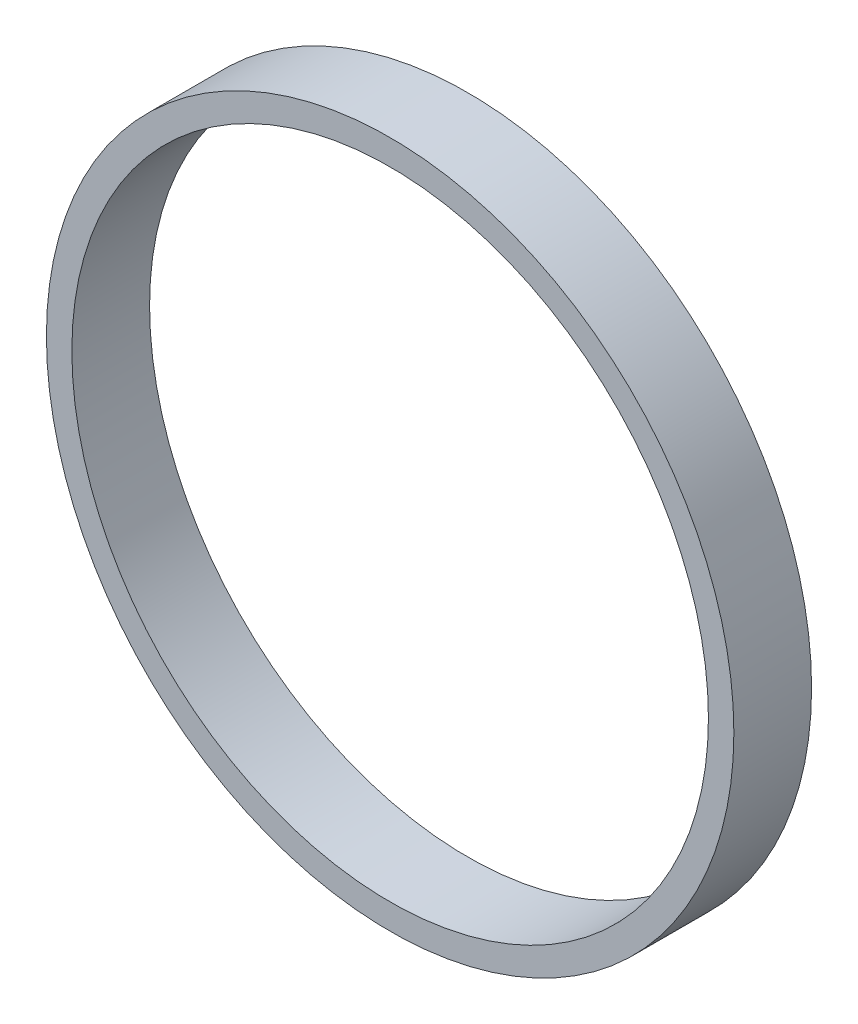
from build123d import *

# Parameters (mm, degrees)
SKETCH1_R           = 24.325
SKETCH1_R_2         = 22.525
BOSS_EXTRUDE1_DEPTH = 5.5


with BuildPart() as part:
    # Sketch1 → Boss-Extrude1 (new body)
    with BuildSketch(Plane.XY):
        Circle(SKETCH1_R)
        Circle(SKETCH1_R_2, mode=Mode.SUBTRACT)
    extrude(amount=BOSS_EXTRUDE1_DEPTH)


solid = part.part
